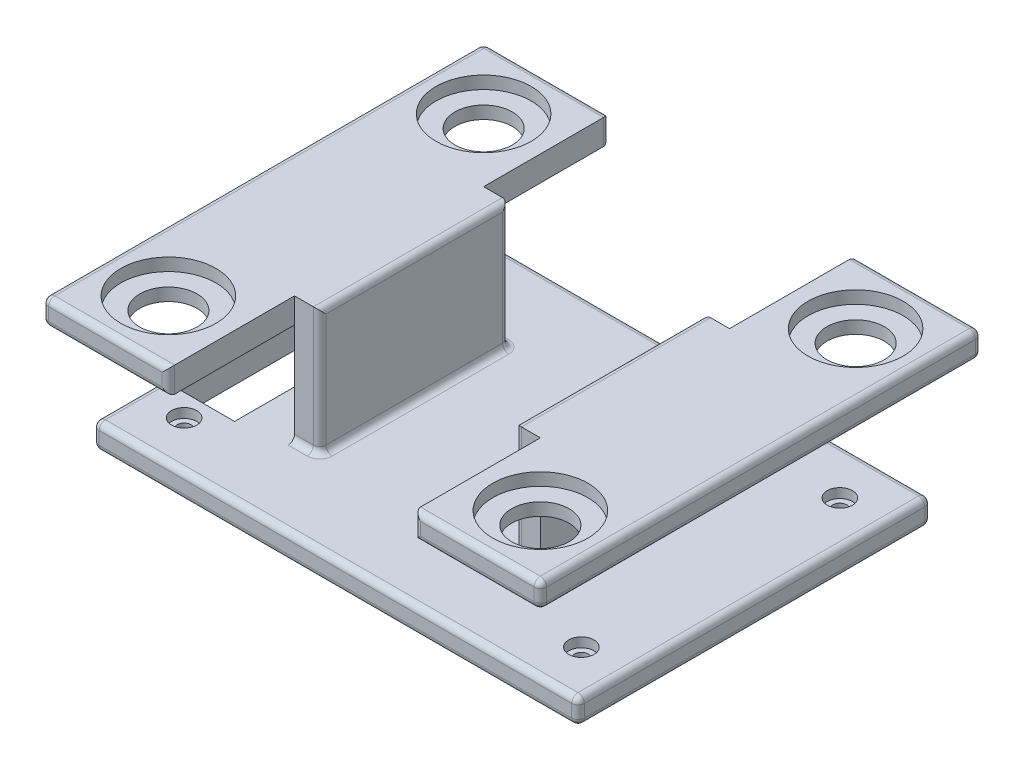
from build123d import *

# Parameters (mm, degrees)
SKETCH1_W           = 76.947055408
SKETCH1_H           = 56
SKETCH1_R           = 1.1
SKETCH1_W_2         = 9
SKETCH1_H_2         = 34
BOSS_EXTRUDE1_DEPTH = 4
SKETCH6_W           = 4
SKETCH6_H           = 30
BOSS_EXTRUDE5_DEPTH = 20
SKETCH7_W           = 70
SKETCH7_H           = 4
BOSS_EXTRUDE6_DEPTH = 20
SKETCH8_R           = 4.55
CUT_EXTRUDE2_DEPTH  = 4
SKETCH9_R           = 7.55
CUT_EXTRUDE3_DEPTH  = 2
SKETCH10_R          = 2
CUT_EXTRUDE4_DEPTH  = 1.5
FILLET4_R           = 1


with BuildPart() as part:
    # Sketch1 → Boss-Extrude1 (new body)
    with BuildSketch(Plane(origin=(0, 0, 0), x_dir=(1, 0, 0), z_dir=(0, 1, 0))):
        Rectangle(SKETCH1_W, SKETCH1_H)
        with Locations((-31.5, 20.5)):
            Circle(SKETCH1_R, mode=Mode.SUBTRACT)
        with Locations((-31.5, -20.5)):
            Circle(SKETCH1_R, mode=Mode.SUBTRACT)
        with Locations((31.5, -20.5)):
            Circle(SKETCH1_R, mode=Mode.SUBTRACT)
        with Locations((31.5, 20.5)):
            Circle(SKETCH1_R, mode=Mode.SUBTRACT)
        with Locations((-31.5, 0)):
            Rectangle(SKETCH1_W_2, SKETCH1_H_2, mode=Mode.SUBTRACT)
    extrude(amount=BOSS_EXTRUDE1_DEPTH)

    # Sketch6 → Boss-Extrude5 (add)
    with BuildSketch(Plane(origin=(0, 4, 0), x_dir=(1, 0, 0), z_dir=(0, 1, 0))):
        with Locations((-17.5, 0)):
            Rectangle(SKETCH6_W, SKETCH6_H)
    boss_extrude5 = extrude(amount=BOSS_EXTRUDE5_DEPTH)

    # Sketch7 → Boss-Extrude6 (add)
    with BuildSketch(Plane.ZY.offset(19.5)):
        with Locations((0, 22)):
            Rectangle(SKETCH7_W, SKETCH7_H)
    boss_extrude6 = extrude(amount=BOSS_EXTRUDE6_DEPTH)

    # Sketch8 → Cut-Extrude2 (cut)
    with BuildSketch(Plane(origin=(0, 24, 0), x_dir=(1, 0, 0), z_dir=(0, 1, 0))):
        with Locations((-29.5, 25)):
            Circle(SKETCH8_R)
        with Locations((-29.5, -25)):
            Circle(SKETCH8_R)
    cut_extrude2 = extrude(amount=-CUT_EXTRUDE2_DEPTH, mode=Mode.SUBTRACT)

    # Sketch9 → Cut-Extrude3 (cut)
    with BuildSketch(Plane(origin=(0, 24, 0), x_dir=(1, 0, 0), z_dir=(0, 1, 0))):
        with Locations((-29.5, 25)):
            Circle(SKETCH9_R)
        with Locations((-29.5, -25)):
            Circle(SKETCH9_R)
    cut_extrude3 = extrude(amount=-CUT_EXTRUDE3_DEPTH, mode=Mode.SUBTRACT)

    # Mirror2: Boss-Extrude5, Boss-Extrude6, Cut-Extrude2, Cut-Extrude3 across plane
    add(boss_extrude5.mirror(Plane(origin=(0, 0, 0), x_dir=(0, 0, 1), z_dir=(1, 0, 0))))
    add(boss_extrude6.mirror(Plane(origin=(0, 0, 0), x_dir=(0, 0, 1), z_dir=(1, 0, 0))))
    add(cut_extrude2.mirror(Plane(origin=(0, 0, 0), x_dir=(0, 0, 1), z_dir=(1, 0, 0))), mode=Mode.SUBTRACT)
    add(cut_extrude3.mirror(Plane(origin=(0, 0, 0), x_dir=(0, 0, 1), z_dir=(1, 0, 0))), mode=Mode.SUBTRACT)

    # Sketch10 → Cut-Extrude4 (cut)
    with BuildSketch(Plane(origin=(0, 4, 0), x_dir=(1, 0, 0), z_dir=(0, 1, 0))):
        with Locations((-31.5, -20.5)):
            Circle(SKETCH10_R)
        with Locations((-31.5, 20.5)):
            Circle(SKETCH10_R)
        with Locations((31.5, 20.5)):
            Circle(SKETCH10_R)
        with Locations((31.5, -20.5)):
            Circle(SKETCH10_R)
    extrude(amount=-CUT_EXTRUDE4_DEPTH, mode=Mode.SUBTRACT)

    # Fillet4
    fillet4_edges = [part.edges().sort_by_distance(p)[0] for p in [
        (-38.473527704, 4, 0),
        (17.5, 4, 15),
        (19.5, 22, 35),
        (39.5, 22, 35),
        (29.5, 24, 35),
        (39.5, 20, 0),
        (29.5, 20, 35),
        (39.5, 22, -35),
        (29.5, 20, -35),
        (39.5, 24, 0),
        (29.5, 24, -35),
        (19.5, 22, -35),
        (0, 4, 28),
        (38.473527704, 4, 0),
        (0, 0, 28),
        (-15.5, 4, 0),
        (-15.5, 14, 15),
        (-17.5, 4, -15),
        (-15.5, 14, -15),
        (-17.5, 4, 15),
        (-15.5, 24, 0),
        (-38.473527704, 0, 0),
        (0, 0, -28),
        (38.473527704, 0, 0),
        (-19.5, 22, 35),
        (-29.5, 20, 35),
        (-29.5, 24, 35),
        (-19.5, 22, -35),
        (-29.5, 24, -35),
        (-29.5, 20, -35),
        (-39.5, 22, 35),
        (-39.5, 24, 0),
        (-39.5, 22, -35),
        (-39.5, 20, 0),
        (0, 4, -28),
        (38.473527704, 2, 28),
        (-38.473527704, 2, 28),
        (-38.473527704, 2, -28),
        (38.473527704, 2, -28),
        (15.5, 24, 0),
        (15.5, 14, -15),
        (15.5, 14, 15),
        (15.5, 4, 0),
        (17.5, 4, -15),
    ]]
    fillet(fillet4_edges, radius=FILLET4_R)


solid = part.part
